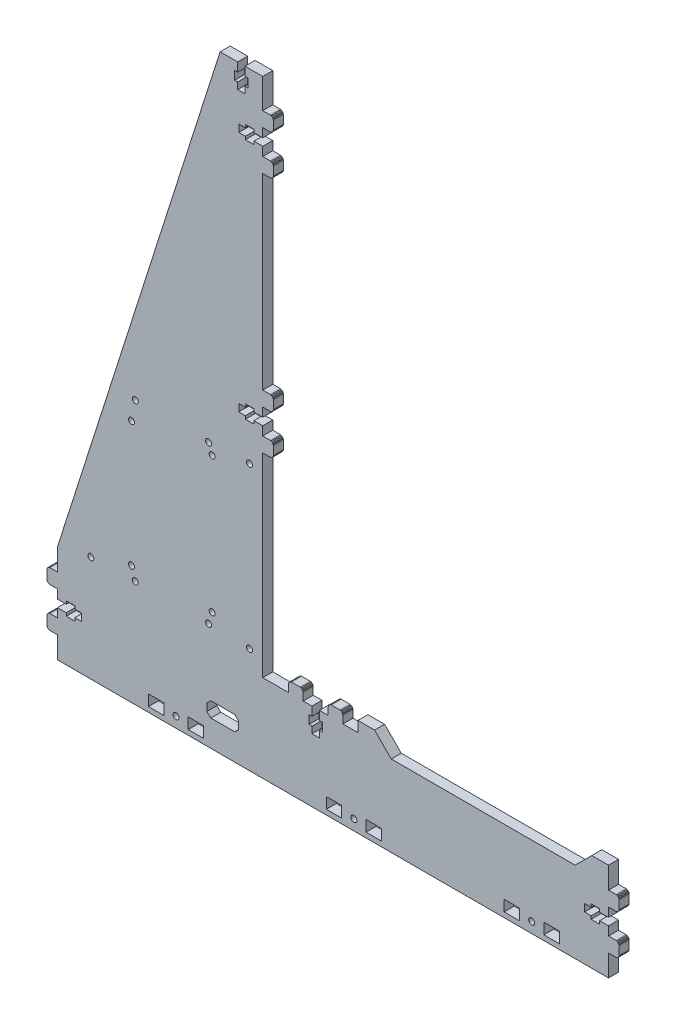
from build123d import *

# Parameters (mm, degrees)
MODEL_R                  = 1.8
MODEL_W                  = 9.1999977
MODEL_H                  = 6.600001917
MODEL_W_2                = 9.199995837
RESSALTO_EXTRUS_O1_DEPTH = 6


with BuildPart() as part:
    # Model → Ressalto-extrusão1 (new body)
    with BuildSketch(Plane.XY):
        Polygon((389.583972566, 57.282050501), (389.583972566, 55.482052269), (385.633972744, 55.482052269), (385.633972744, 51.082047598), (389.583972566, 51.082047598), (389.583972566, 49.282049366), (394.683970331, 49.282049366), (394.683970331, 51.082047598), (399.983969153, 51.082047598), (399.983969153, 45.782050343), (404.333967044, 45.782050343), (404.851605134, 45.713901995), (405.333967044, 45.51410115), (405.748180606, 45.196263905), (406.066017851, 44.782050343), (406.265818696, 44.299688433), (406.333967044, 43.782050343), (406.333967044, 38.982055901), (406.265818696, 38.46441781), (406.066017851, 37.982055901), (405.748180606, 37.567842338), (405.333967044, 37.250005093), (404.851605134, 37.050204248), (404.333967044, 36.982055901), (399.983969153, 36.982055901), (399.983969153, 24.032059294), (70.084074721, 24.032059294), (70.084074721, 36.982059626), (65.734076829, 36.982059626), (65.216438739, 37.050207973), (64.734076829, 37.250008818), (64.319863267, 37.567846063), (64.002026022, 37.982059626), (63.802225177, 38.464421536), (63.734076829, 38.982059626), (63.734076829, 43.782055591), (63.802225177, 44.299693681), (64.002026022, 44.782055591), (64.319863267, 45.196269153), (64.734076829, 45.514106398), (65.216438739, 45.713907244), (65.734076829, 45.782055591), (70.084074721, 45.782055591), (70.084074721, 51.082047598), (75.384073542, 51.082047598), (75.384073542, 49.282049366), (80.484071307, 49.282049366), (80.484071307, 51.082047598), (84.434071129, 51.082047598), (84.434071129, 55.482052269), (80.484071307, 55.482052269), (80.484071307, 57.282050501), (75.384073542, 57.282050501), (75.384073542, 55.482052269), (70.084074721, 55.482052269), (70.084074721, 60.782049524), (65.734076829, 60.782049524), (65.216438739, 60.850197872), (64.734076829, 61.049998717), (64.319863267, 61.367835962), (64.002026022, 61.782049524), (63.802225177, 62.264411434), (63.734076829, 62.782049524), (63.734076829, 67.582043967), (63.802225177, 68.099682057), (64.002026022, 68.582043967), (64.319863267, 68.996257529), (64.734076829, 69.314094774), (65.216438739, 69.513895619), (65.734076829, 69.582043967), (70.084074721, 69.582043967), (70.084074721, 82.532040574), (167.475744407, 387.931942846), (177.984037153, 387.931942846), (177.984037153, 382.631944024), (176.184038921, 382.631944024), (176.184038921, 377.531946259), (177.984037153, 377.531946259), (177.984037153, 373.581946437), (182.384041825, 373.581946437), (182.384041825, 377.531946259), (184.184040056, 377.531946259), (184.184040056, 382.631944024), (182.384041825, 382.631944024), (182.384041825, 387.931942846), (192.984035393, 387.931942846), (192.984035393, 370.199303113), (197.334033284, 370.199303113), (197.851671374, 370.131154766), (198.334033284, 369.931353921), (198.748246846, 369.613516676), (199.066084091, 369.199303113), (199.265884936, 368.716941203), (199.334033284, 368.199303113), (199.334033284, 363.399307148), (199.265884936, 362.881669058), (199.066084091, 362.399307148), (198.748246846, 361.985093586), (198.334033284, 361.667256341), (197.851671374, 361.467455496), (197.334033284, 361.399307148), (192.984035393, 361.399307148), (192.984035393, 356.099315141), (187.684036571, 356.099315141), (187.684036571, 357.899313373), (182.584038806, 357.899313373), (182.584038806, 356.099315141), (178.634038984, 356.099315141), (178.634038984, 351.69931047), (182.584038806, 351.69931047), (182.584038806, 349.899312238), (187.684036571, 349.899312238), (187.684036571, 351.69931047), (192.984035393, 351.69931047), (192.984035393, 346.399313215), (197.334033284, 346.399313215), (197.851671374, 346.331164867), (198.334033284, 346.131364022), (198.748246846, 345.813526777), (199.066084091, 345.399313215), (199.265884936, 344.916951305), (199.334033284, 344.399313215), (199.334033284, 339.599318773), (199.265884936, 339.081680682), (199.066084091, 338.599318773), (198.748246846, 338.18510521), (198.334033284, 337.867267965), (197.851671374, 337.66746712), (197.334033284, 337.599318773), (192.984035393, 337.599318773), (192.984035393, 225.331990401), (197.334033284, 225.331990401), (197.851671374, 225.263842054), (198.334033284, 225.064041209), (198.748246846, 224.746203964), (199.066084091, 224.331990401), (199.265884936, 223.849628492), (199.334033284, 223.331990401), (199.334033284, 218.531994436), (199.265884936, 218.014356346), (199.066084091, 217.531994436), (198.748246846, 217.117780874), (198.334033284, 216.799943629), (197.851671374, 216.600142784), (197.334033284, 216.531994436), (192.984035393, 216.531994436), (192.984035393, 211.232002429), (187.684036571, 211.232002429), (187.684036571, 213.032000661), (182.584038806, 213.032000661), (182.584038806, 211.232002429), (178.634038984, 211.232002429), (178.634038984, 206.831997758), (182.584038806, 206.831997758), (182.584038806, 205.031999526), (187.684036571, 205.031999526), (187.684036571, 206.831997758), (192.984035393, 206.831997758), (192.984035393, 201.532000503), (197.334033284, 201.532000503), (197.851671374, 201.463852155), (198.334033284, 201.26405131), (198.748246846, 200.946214065), (199.066084091, 200.532000503), (199.265884936, 200.049638593), (199.334033284, 199.532000503), (199.334033284, 194.732006061), (199.265884936, 194.21436797), (199.066084091, 193.732006061), (198.748246846, 193.317792498), (198.334033284, 192.999955253), (197.851671374, 192.800154408), (197.334033284, 192.732006061), (192.984035393, 192.732006061), (192.984035393, 76.232041078), (208.384032553, 76.232041078), (208.384032553, 80.582038969), (208.4521809, 81.099677059), (208.651981745, 81.582038969), (208.96981899, 81.996252531), (209.384032553, 82.314089776), (209.866394462, 82.513890621), (210.384032553, 82.582038969), (215.184026995, 82.582038969), (215.701665085, 82.513890621), (216.184026995, 82.314089776), (216.598240557, 81.996252531), (216.916077802, 81.582038969), (217.115878647, 81.099677059), (217.184026995, 80.582038969), (217.184026995, 76.232041078), (222.48402425, 76.232041078), (222.48402425, 70.932042256), (220.684026018, 70.932042256), (220.684026018, 65.832044491), (222.48402425, 65.832044491), (222.48402425, 61.882044669), (226.884028921, 61.882044669), (226.884028921, 65.832044491), (228.684027153, 65.832044491), (228.684027153, 70.932042256), (226.884028921, 70.932042256), (226.884028921, 76.232041078), (232.184020928, 76.232041078), (232.184020928, 80.582038969), (232.252169276, 81.099677059), (232.451970121, 81.582038969), (232.769807366, 81.996252531), (233.184020928, 82.314089776), (233.666382838, 82.513890621), (234.184020928, 82.582038969), (238.984016893, 82.582038969), (239.501654984, 82.513890621), (239.984016893, 82.314089776), (240.398230456, 81.996252531), (240.716067701, 81.582038969), (240.915868546, 81.099677059), (240.984016893, 80.582038969), (240.984016893, 76.232041078), (249.927288754, 76.232041078), (249.927288754, 82.532040574), (259.927287954, 82.532040574), (269.927287154, 72.532041374), (379.983970753, 72.532041374), (389.983969953, 82.532040574), (399.983969153, 82.532040574), (399.983969153, 69.582040241), (404.333967044, 69.582040241), (404.851605134, 69.513891894), (405.333967044, 69.314091049), (405.748180606, 68.996253804), (406.066017851, 68.582040241), (406.265818696, 68.099678332), (406.333967044, 67.582040241), (406.333967044, 62.782044276), (406.265818696, 62.264406186), (406.066017851, 61.782044276), (405.748180606, 61.367830714), (405.333967044, 61.049993469), (404.851605134, 60.850192624), (404.333967044, 60.782044276), (399.983969153, 60.782044276), (399.983969153, 55.482052269), (394.683970331, 55.482052269), (394.683970331, 57.282050501), align=None)
        with Locations((353.983983873, 30.332057278)):
            Circle(MODEL_R, mode=Mode.SUBTRACT)
        with Locations((247.534017937, 30.332057278)):
            Circle(MODEL_R, mode=Mode.SUBTRACT)
        with Locations((141.084052001, 30.332057278)):
            Circle(MODEL_R, mode=Mode.SUBTRACT)
        with Locations((185.075147904, 87.254262445)):
            Circle(MODEL_R, mode=Mode.SUBTRACT)
        with Locations((160.579755838, 88.021355256)):
            Circle(MODEL_R, mode=Mode.SUBTRACT)
        with Locations((162.718937424, 95.038938614)):
            Circle(MODEL_R, mode=Mode.SUBTRACT)
        with Locations((116.648123011, 88.021389135)):
            Circle(MODEL_R, mode=Mode.SUBTRACT)
        with Locations((114.458737791, 95.110435206)):
            Circle(MODEL_R, mode=Mode.SUBTRACT)
        with Locations((90.082097728, 87.297837239)):
            Circle(MODEL_R, mode=Mode.SUBTRACT)
        with Locations((185.051413195, 183.210760345)):
            Circle(MODEL_R, mode=Mode.SUBTRACT)
        with Locations((162.688960504, 176.355625851)):
            Circle(MODEL_R, mode=Mode.SUBTRACT)
        with Locations((160.547721974, 182.038002519)):
            Circle(MODEL_R, mode=Mode.SUBTRACT)
        with Locations((114.425791066, 170.05495099)):
            Circle(MODEL_R, mode=Mode.SUBTRACT)
        with Locations((116.713528466, 181.945784032)):
            Circle(MODEL_R, mode=Mode.SUBTRACT)
        with Locations((342.083989093, 30.332058239)):
            Rectangle(MODEL_W, MODEL_H, mode=Mode.SUBTRACT)
        with Locations((259.434013988, 30.332058239)):
            Rectangle(MODEL_W_2, MODEL_H, mode=Mode.SUBTRACT)
        with Locations((129.184057221, 30.332058239)):
            Rectangle(MODEL_W, MODEL_H, mode=Mode.SUBTRACT)
        with Locations((235.634023157, 30.332058239)):
            Rectangle(MODEL_W, MODEL_H, mode=Mode.SUBTRACT)
        with Locations((152.984048051, 30.332058239)):
            Rectangle(MODEL_W_2, MODEL_H, mode=Mode.SUBTRACT)
        Polygon((159.531560457, 41.992054263), (159.531560457, 46.472051396), (161.911560457, 48.712051396), (176.186758329, 48.712051396), (178.566758329, 46.472051396), (178.566758329, 41.992054263), (176.186758329, 39.752054263), (161.911560457, 39.752054263), align=None, mode=Mode.SUBTRACT)
        with Locations((365.883979924, 30.332058239)):
            Rectangle(MODEL_W_2, MODEL_H, mode=Mode.SUBTRACT)
    extrude(amount=RESSALTO_EXTRUS_O1_DEPTH)


solid = part.part
